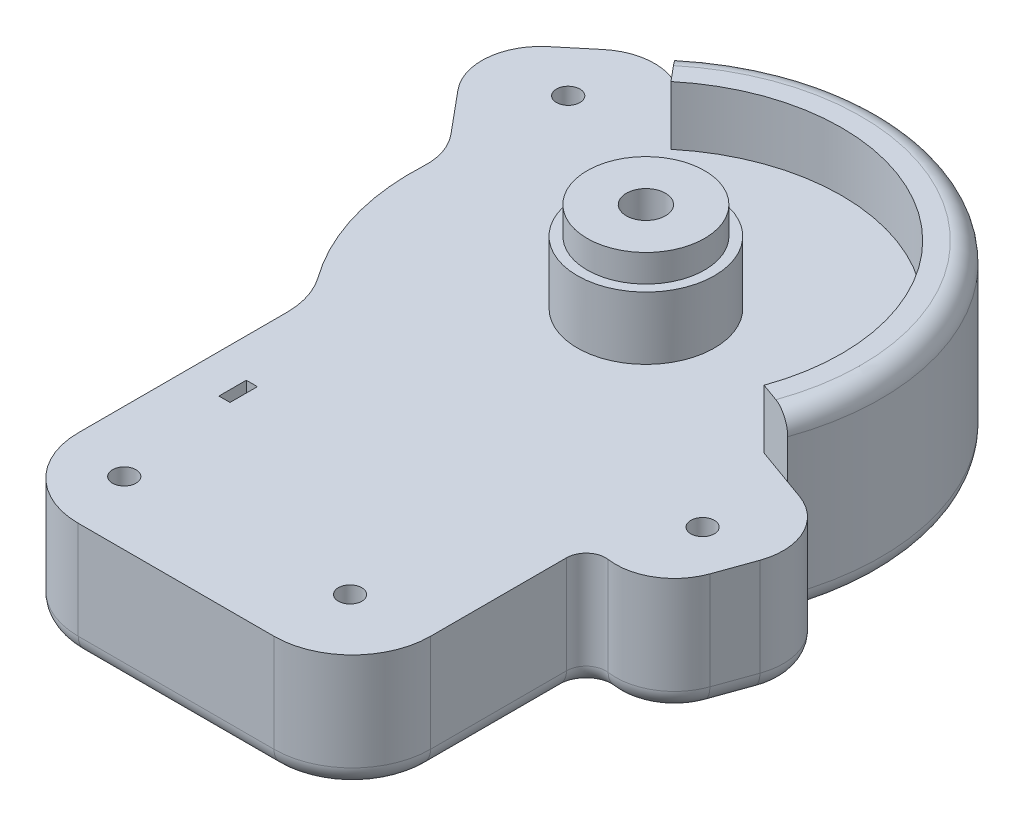
from build123d import *

# Parameters (mm, degrees)
BOSS_EXTRUDE1_DEPTH = 30
SKETCH3_R           = 6
CUT_EXTRUDE2_DEPTH  = 10
CUT_EXTRUDE3_REACH  = 22
SKETCH4_R           = 3
SKETCH5_R           = 17.5
BOSS_EXTRUDE2_DEPTH = 16
SKETCH6_R           = 15
BOSS_EXTRUDE3_DEPTH = 7
BOSS_EXTRUDE4_DEPTH = 15
FILLET1_R           = 5
CUT_EXTRUDE4_REACH  = 55
SKETCH8_R           = 5
CUT_EXTRUDE5_REACH  = 32
SKETCH9_W           = 2.838035454
SKETCH9_H           = 7.000000767
CUT_EXTRUDE6_DEPTH  = 10


with BuildPart() as part:
    # Sketch1 → Boss-Extrude1 (new body)
    with BuildSketch(Plane(origin=(0, 0, 0), x_dir=(-1, 0, 0), z_dir=(0, -1, 0))):
        with BuildLine():
            Line((-155.978842812, -669.571630145), (-160.685424707, -671.259257732))
            ThreePointArc((-160.685424707, -671.259257732), (-169.1867086, -678.974834226), (-169.742287629, -690.441886175))
            Line((-169.742287629, -690.441886175), (-166.367032456, -699.855049964))
            ThreePointArc((-166.367032456, -699.855049964), (-160.015233889, -707.624119417), (-150.186716753, -709.649961495))
            ThreePointArc((-150.186716753, -709.649961495), (-146.216133795, -710.831997076), (-144.49986008, -714.602559592))
            Line((-144.49986008, -714.602559592), (-144.49986008, -749.320099104))
            ThreePointArc((-144.49986008, -749.320099104), (-138.641995704, -763.462234727), (-124.49986008, -769.320099104))
            Line((-124.49986008, -769.320099104), (-74.49986008, -769.320099104))
            ThreePointArc((-74.49986008, -769.320099104), (-60.357724456, -763.462234727), (-54.49986008, -749.320099104))
            Line((-54.49986008, -749.320099104), (-54.49986008, -695.956994369))
            ThreePointArc((-54.49986008, -695.956994369), (-53.539292845, -689.833270012), (-50.74986008, -684.297770553))
            ThreePointArc((-50.74986008, -684.297770553), (-41.916134266, -666.175796103), (-39.583621808, -646.150810326))
            ThreePointArc((-39.583621808, -646.150810326), (-38.838622962, -640.626520742), (-36.127881434, -635.755722136))
            Line((-36.127881434, -635.755722136), (-27.159022918, -624.993091916))
            ThreePointArc((-27.159022918, -624.993091916), (-23.743944015, -614.032289731), (-29.079576117, -603.867006728))
            Line((-29.079576117, -603.867006728), (-36.761788913, -597.465162731))
            ThreePointArc((-36.761788913, -597.465162731), (-47.722591099, -594.050083828), (-57.887874102, -599.38571593))
            Line((-57.887874102, -599.38571593), (-61.0887961, -603.226822328))
            ThreePointArc((-61.0887961, -603.226822328), (-133.880389498, -600.14714722), (-155.978842812, -669.571630145))
        make_face()
    extrude(amount=BOSS_EXTRUDE1_DEPTH)

    # Sketch3 → Cut-Extrude2 (cut)
    with BuildSketch(Plane.XZ.offset(30)):
        with Locations((42.52344851, 612.189403923)):
            Circle(SKETCH3_R)
        with Locations((155.092642393, 690.430908662)):
            Circle(SKETCH3_R)
        with Locations((124.976355339, 750.357765174)):
            Circle(SKETCH3_R)
        with Locations((70.026025263, 753.095100306)):
            Circle(SKETCH3_R)
    extrude(amount=-CUT_EXTRUDE2_DEPTH, mode=Mode.SUBTRACT)

    # Sketch4 → Cut-Extrude3 (cut, up to next)
    with BuildSketch(Plane.XZ.offset(20), mode=Mode.PRIVATE) as cut_extrude3_sk1:
        with Locations((42.52344851, 612.189403923)):
            Circle(SKETCH4_R)
    cut_extrude3_tool1 = extrude(cut_extrude3_sk1.sketch, amount=-CUT_EXTRUDE3_REACH, mode=Mode.PRIVATE) & part.part
    add(cut_extrude3_tool1.solids().sort_by_distance((42.523449, -20, 612.189404))[0], mode=Mode.SUBTRACT)
    # Sketch4 → Cut-Extrude3 (cut, up to next)
    with BuildSketch(Plane.XZ.offset(20), mode=Mode.PRIVATE) as cut_extrude3_sk2:
        with Locations((155.092642393, 690.430908662)):
            Circle(SKETCH4_R)
    cut_extrude3_tool2 = extrude(cut_extrude3_sk2.sketch, amount=-CUT_EXTRUDE3_REACH, mode=Mode.PRIVATE) & part.part
    add(cut_extrude3_tool2.solids().sort_by_distance((155.092642, -20, 690.430909))[0], mode=Mode.SUBTRACT)
    # Sketch4 → Cut-Extrude3 (cut, up to next)
    with BuildSketch(Plane.XZ.offset(20), mode=Mode.PRIVATE) as cut_extrude3_sk3:
        with Locations((124.976355339, 750.357765174)):
            Circle(SKETCH4_R)
    cut_extrude3_tool3 = extrude(cut_extrude3_sk3.sketch, amount=-CUT_EXTRUDE3_REACH, mode=Mode.PRIVATE) & part.part
    add(cut_extrude3_tool3.solids().sort_by_distance((124.976355, -20, 750.357765))[0], mode=Mode.SUBTRACT)
    # Sketch4 → Cut-Extrude3 (cut, up to next)
    with BuildSketch(Plane.XZ.offset(20), mode=Mode.PRIVATE) as cut_extrude3_sk4:
        with Locations((70.026025263, 753.095100306)):
            Circle(SKETCH4_R)
    cut_extrude3_tool4 = extrude(cut_extrude3_sk4.sketch, amount=-CUT_EXTRUDE3_REACH, mode=Mode.PRIVATE) & part.part
    add(cut_extrude3_tool4.solids().sort_by_distance((70.026025, -20, 753.0951))[0], mode=Mode.SUBTRACT)

    # Sketch5 → Boss-Extrude2 (add)
    with BuildSketch(Plane(origin=(0, 0, 0), x_dir=(1, 0, 0), z_dir=(0, 1, 0))):
        with Locations((99.49986008, -649.320099104)):
            Circle(SKETCH5_R)
    extrude(amount=BOSS_EXTRUDE2_DEPTH)

    # Sketch6 → Boss-Extrude3 (add)
    with BuildSketch(Plane(origin=(0, 16, 0), x_dir=(1, 0, 0), z_dir=(0, 1, 0))):
        with Locations((99.49986008, -649.320099104)):
            Circle(SKETCH6_R)
    extrude(amount=BOSS_EXTRUDE3_DEPTH)

    # Sketch7 → Boss-Extrude4 (add)
    with BuildSketch(Plane(origin=(0, 0, 0), x_dir=(1, 0, 0), z_dir=(0, 1, 0))):
        with BuildLine():
            Line((155.978842812, -669.571630145), (146.565591992, -666.196355925))
            ThreePointArc((146.565591992, -666.196355925), (128.150229883, -608.342615172), (67.490568023, -610.908994684))
            Line((67.490568023, -610.908994684), (61.0887961, -603.226822328))
            ThreePointArc((61.0887961, -603.226822328), (133.880389498, -600.14714722), (155.978842812, -669.571630145))
        make_face()
    extrude(amount=BOSS_EXTRUDE4_DEPTH)

    # Fillet1
    fillet1_edges = [part.edges().sort_by_distance(p)[0] for p in [
        (133.880389498, 15, 600.14714722),
        (23.743944015, -30, 614.032289731),
        (32.920682515, -30, 600.666084729),
        (47.722591099, -30, 594.050083828),
        (59.488335101, -30, 601.306269129),
        (133.880389498, -30, 600.14714722),
        (158.332133759, -30, 670.415443939),
        (169.1867086, -30, 678.974834226),
        (168.054660043, -30, 695.14846807),
        (160.015233889, -30, 707.624119417),
        (146.216133795, -30, 710.831997076),
        (38.838622962, -30, 640.626520742),
        (144.49986008, -30, 731.961329348),
        (138.641995704, -30, 763.462234727),
        (99.49986008, -30, 769.320099104),
        (60.357724456, -30, 763.462234727),
        (54.49986008, -30, 722.638546736),
        (53.539292845, -30, 689.833270012),
        (41.916134266, -30, 666.175796103),
        (31.643452176, -30, 630.374407026),
    ]]
    fillet(fillet1_edges, radius=FILLET1_R)

    # Sketch8 → Cut-Extrude4 (cut, up to next)
    with BuildSketch(Plane(origin=(0, 23, 0), x_dir=(1, 0, 0), z_dir=(0, 1, 0)), mode=Mode.PRIVATE) as cut_extrude4_sk1:
        with Locations((99.49986008, -649.320099104)):
            Circle(SKETCH8_R)
    cut_extrude4_tool1 = extrude(cut_extrude4_sk1.sketch, amount=-CUT_EXTRUDE4_REACH, mode=Mode.PRIVATE) & part.part
    add(cut_extrude4_tool1.solids().sort_by_distance((99.49986, 23, 649.320099))[0], mode=Mode.SUBTRACT)

    # Sketch9 → Cut-Extrude5 (cut, up to next)
    with BuildSketch(Plane(origin=(0, 0, 0), x_dir=(1, 0, 0), z_dir=(0, 1, 0)), mode=Mode.PRIVATE) as cut_extrude5_sk1:
        with Locations((65.749484781, -719.720058193)):
            Rectangle(SKETCH9_W, SKETCH9_H)
    cut_extrude5_tool1 = extrude(cut_extrude5_sk1.sketch, amount=-CUT_EXTRUDE5_REACH, mode=Mode.PRIVATE) & part.part
    add(cut_extrude5_tool1.solids().sort_by_distance((65.749485, 0, 719.720058))[0], mode=Mode.SUBTRACT)

    # Sketch11 → Cut-Extrude6 (cut)
    with BuildSketch(Plane.XZ.offset(30)):
        with BuildLine():
            Line((67.168502508, 716.220057809), (87.168502508, 716.220057809))
            ThreePointArc((87.168502508, 716.220057809), (92.788209532, 714.505914445), (95.54986008, 709.320099104))
            Line((95.54986008, 709.320099104), (95.54986008, 649.320099104))
            Line((95.54986008, 649.320099104), (103.44986008, 649.320099104))
            Line((103.44986008, 649.320099104), (103.44986008, 709.320099104))
            ThreePointArc((103.44986008, 709.320099104), (98.187957159, 719.6420584), (87.168502508, 723.220058576))
            Line((87.168502508, 723.220058576), (67.168502508, 723.220058576))
            Line((67.168502508, 723.220058576), (67.168502508, 716.220057809))
        make_face()
    extrude(amount=-CUT_EXTRUDE6_DEPTH, mode=Mode.SUBTRACT)


solid = part.part
